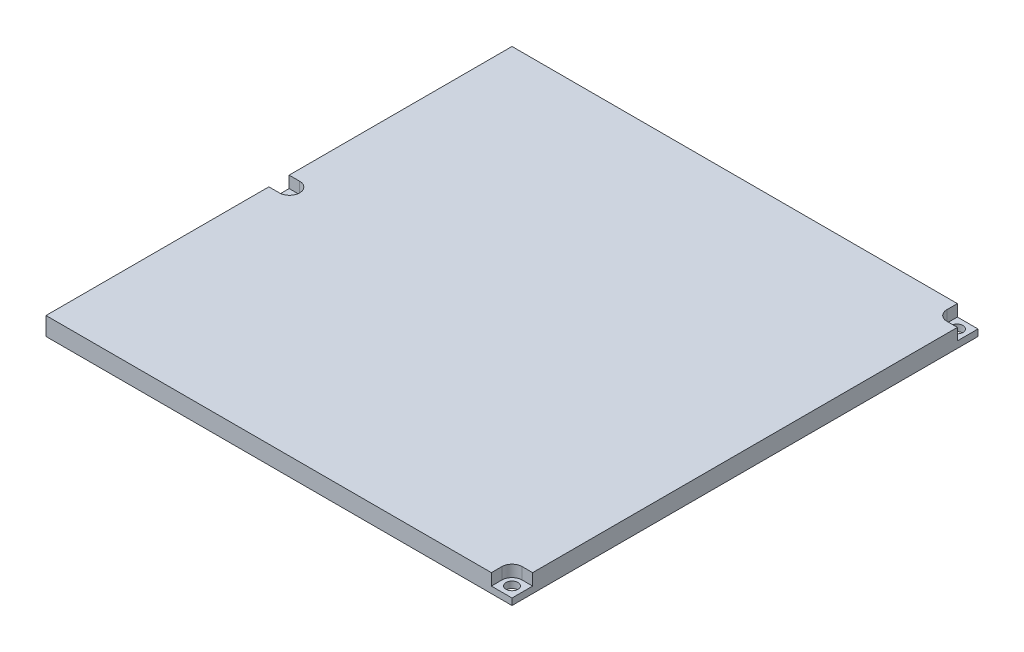
from build123d import *

# Parameters (mm, degrees)
SKETCH1_W           = 203.2
SKETCH1_H           = 203.2
BOSS_EXTRUDE1_DEPTH = 7.9375
HOLES_REACH         = 9.938
SKETCH3_R           = 2.60985
SKETCH4_R           = 2.60985
COUNTERS_DEPTH      = 5.08


with BuildPart() as part:
    # Sketch1 → Boss-Extrude1 (new body)
    with BuildSketch(Plane(origin=(0, 0, 0), x_dir=(1, 0, 0), z_dir=(0, 1, 0))):
        with Locations((101.6, 101.6)):
            Rectangle(SKETCH1_W, SKETCH1_H)
    extrude(amount=BOSS_EXTRUDE1_DEPTH)

    # Sketch3 → holes (cut, up to next)
    with BuildSketch(Plane(origin=(0, 7.9375, 0), x_dir=(1, 0, 0), z_dir=(0, 1, 0)), mode=Mode.PRIVATE) as holes_sk1:
        with Locations((4.572, 101.6)):
            Circle(SKETCH3_R)
    holes_tool1 = extrude(holes_sk1.sketch, amount=-HOLES_REACH, mode=Mode.PRIVATE) & part.part
    add(holes_tool1.solids().sort_by_distance((4.572, 7.9375, -101.6))[0], mode=Mode.SUBTRACT)
    # Sketch3 → holes (cut, up to next)
    with BuildSketch(Plane(origin=(0, 7.9375, 0), x_dir=(1, 0, 0), z_dir=(0, 1, 0)), mode=Mode.PRIVATE) as holes_sk2:
        with Locations((198.628, 198.628)):
            Circle(SKETCH3_R)
    holes_tool2 = extrude(holes_sk2.sketch, amount=-HOLES_REACH, mode=Mode.PRIVATE) & part.part
    add(holes_tool2.solids().sort_by_distance((198.628, 7.9375, -198.628))[0], mode=Mode.SUBTRACT)
    # Sketch3 → holes (cut, up to next)
    with BuildSketch(Plane(origin=(0, 7.9375, 0), x_dir=(1, 0, 0), z_dir=(0, 1, 0)), mode=Mode.PRIVATE) as holes_sk3:
        with Locations((198.628, 4.572)):
            Circle(SKETCH3_R)
    holes_tool3 = extrude(holes_sk3.sketch, amount=-HOLES_REACH, mode=Mode.PRIVATE) & part.part
    add(holes_tool3.solids().sort_by_distance((198.628, 7.9375, -4.572))[0], mode=Mode.SUBTRACT)

    # Sketch4 → counters (cut)
    with BuildSketch(Plane(origin=(0, 7.9375, 0), x_dir=(1, 0, 0), z_dir=(0, 1, 0))):
        with BuildLine():
            Line((4.572, 106.0196), (0, 106.0196))
            Line((0, 106.0196), (0, 97.1804))
            Line((0, 97.1804), (4.572, 97.1804))
            ThreePointArc((4.572, 97.1804), (8.9916, 101.6), (4.572, 106.0196))
        make_face()
        with Locations((4.572, 101.6)):
            Circle(SKETCH4_R, mode=Mode.SUBTRACT)
        with BuildLine():
            Line((194.2084, 198.628), (194.2084, 203.2))
            Line((194.2084, 203.2), (203.2, 203.2))
            Line((203.2, 203.2), (203.2, 194.2084))
            Line((203.2, 194.2084), (198.628, 194.2084))
            ThreePointArc((198.628, 194.2084), (195.50287087, 195.50287087), (194.2084, 198.628))
        make_face()
        with Locations((198.628, 198.628)):
            Circle(SKETCH4_R, mode=Mode.SUBTRACT)
        with BuildLine():
            Line((194.2084, 4.572), (194.2084, 0))
            Line((194.2084, 0), (203.2, 0))
            Line((203.2, 0), (203.2, 8.9916))
            Line((203.2, 8.9916), (198.628, 8.9916))
            ThreePointArc((198.628, 8.9916), (195.50287087, 7.69712913), (194.2084, 4.572))
        make_face()
        with Locations((198.628, 4.572)):
            Circle(SKETCH4_R, mode=Mode.SUBTRACT)
    extrude(amount=-COUNTERS_DEPTH, mode=Mode.SUBTRACT)


solid = part.part
